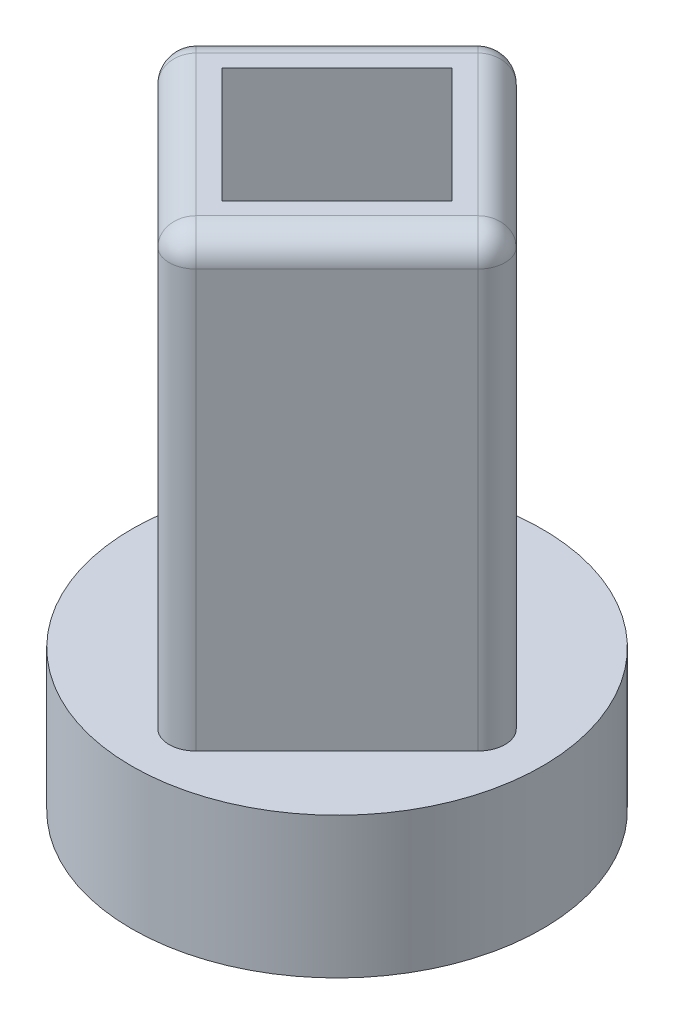
from build123d import *

# Parameters (mm, degrees)
SKETCH1_R           = 7.575
BOSS_EXTRUDE1_DEPTH = 5.2
CUT_EXTRUDE1_DEPTH  = 3.6
BOSS_EXTRUDE2_DEPTH = 16.4
FILLET1_R           = 1
BOSS_EXTRUDE3_DEPTH = 4.85
SKETCH6_R           = 1.875
BOSS_EXTRUDE4_DEPTH = 2.55
CUT_EXTRUDE2_DEPTH  = 4


with BuildPart() as part:
    # Sketch1 → Boss-Extrude1 (new body)
    with BuildSketch(Plane(origin=(0, 0, 0), x_dir=(1, 0, 0), z_dir=(0, 1, 0))):
        Circle(SKETCH1_R)
    extrude(amount=BOSS_EXTRUDE1_DEPTH)

    # Sketch2 → Cut-Extrude1 (cut)
    with BuildSketch(Plane.XZ):
        with BuildLine():
            Line((-4.359330502, -1.388114754), (0, -4.575))
            ThreePointArc((0, -4.575), (2.7, 3.693321676), (-4.359330502, -1.388114754))
        make_face()
    extrude(amount=-CUT_EXTRUDE1_DEPTH, mode=Mode.SUBTRACT)

    # Sketch4 → Boss-Extrude2 (add)
    with BuildSketch(Plane(origin=(0, 5.2, 0), x_dir=(1, 0, 0), z_dir=(0, 1, 0))):
        Polygon((6.611448404, 0), (0, 6.611448404), (-6.611448404, 0), (0, -6.611448404), align=None)
        Polygon((4.242640687, 0), (0, 4.242640687), (-4.242640687, 0), (0, -4.242640687), align=None, mode=Mode.SUBTRACT)
    extrude(amount=BOSS_EXTRUDE2_DEPTH)

    # Fillet1
    fillet1_edges = [part.edges().sort_by_distance(p)[0] for p in [
        (3.305724202, 21.6, 3.305724202),
        (3.305724202, 21.6, -3.305724202),
        (-3.305724202, 21.6, -3.305724202),
        (-3.305724202, 21.6, 3.305724202),
        (0, 13.4, 6.611448404),
        (6.611448404, 13.4, 0),
        (0, 13.4, -6.611448404),
        (-6.611448404, 13.4, 0),
    ]]
    fillet(fillet1_edges, radius=FILLET1_R)

    # Sketch5 → Boss-Extrude3 (add)
    with BuildSketch(Plane(origin=(0, 5.2, 0), x_dir=(1, 0, 0), z_dir=(0, 1, 0))):
        Polygon((0, -4.242640687), (4.242640687, 0), (0, 4.242640687), (-4.242640687, 0), align=None)
    extrude(amount=BOSS_EXTRUDE3_DEPTH)

    # Sketch6 → Boss-Extrude4 (add)
    with BuildSketch(Plane(origin=(0, 10.05, 0), x_dir=(1, 0, 0), z_dir=(0, 1, 0))):
        Circle(SKETCH6_R)
    extrude(amount=BOSS_EXTRUDE4_DEPTH)

    # Sketch3 → Cut-Extrude2 (cut)
    with BuildSketch(Plane.XZ.offset(-3.6)):
        with BuildLine():
            Line((-1.9, 2.157689737), (1.9, 2.157689737))
            ThreePointArc((1.9, 2.157689737), (0, -2.875), (-1.9, 2.157689737))
        make_face()
    extrude(amount=-CUT_EXTRUDE2_DEPTH, mode=Mode.SUBTRACT)


solid = part.part
